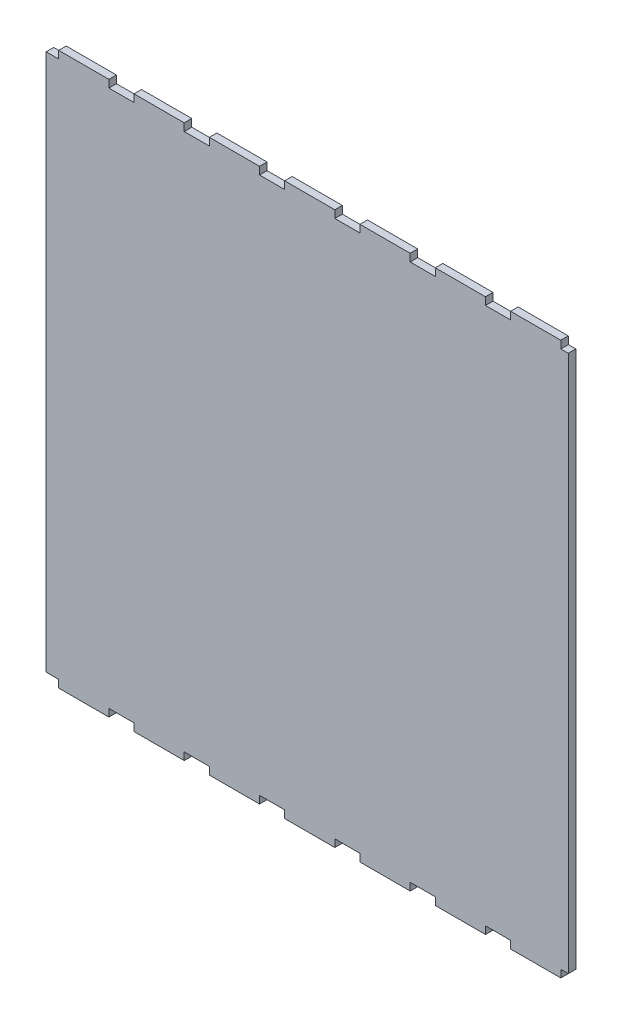
from build123d import *

# Parameters (mm, degrees)
ESQUISSE1_W             = 208
ESQUISSE1_H             = 220
BOSS_EXTRU_1_DEPTH      = 3
ESQUISSE2_W             = 10
ESQUISSE2_H             = 3
ENL_V_MAT_EXTRU_1_DEPTH = 3


with BuildPart() as part:
    # Esquisse1 → Boss.-Extru.1 (new body)
    with BuildSketch(Plane.XY):
        Rectangle(ESQUISSE1_W, ESQUISSE1_H)
    extrude(amount=BOSS_EXTRU_1_DEPTH)

    # Esquisse2 → Enlèv. mat.-Extru.1 (cut)
    with BuildSketch(Plane.XY.offset(3)):
        with Locations((-104, 108.5)):
            Rectangle(ESQUISSE2_W, ESQUISSE2_H)
        with Locations((-74, 108.5)):
            Rectangle(ESQUISSE2_W, ESQUISSE2_H)
        with Locations((-44, 108.5)):
            Rectangle(ESQUISSE2_W, ESQUISSE2_H)
        with Locations((-14, 108.5)):
            Rectangle(ESQUISSE2_W, ESQUISSE2_H)
        with Locations((16, 108.5)):
            Rectangle(ESQUISSE2_W, ESQUISSE2_H)
        with Locations((46, 108.5)):
            Rectangle(ESQUISSE2_W, ESQUISSE2_H)
        with Locations((76, 108.5)):
            Rectangle(ESQUISSE2_W, ESQUISSE2_H)
        with Locations((106, 108.5)):
            Rectangle(ESQUISSE2_W, ESQUISSE2_H)
        with Locations((106, -108.5)):
            Rectangle(ESQUISSE2_W, ESQUISSE2_H)
        with Locations((76, -108.5)):
            Rectangle(ESQUISSE2_W, ESQUISSE2_H)
        with Locations((46, -108.5)):
            Rectangle(ESQUISSE2_W, ESQUISSE2_H)
        with Locations((16, -108.5)):
            Rectangle(ESQUISSE2_W, ESQUISSE2_H)
        with Locations((-14, -108.5)):
            Rectangle(ESQUISSE2_W, ESQUISSE2_H)
        with Locations((-44, -108.5)):
            Rectangle(ESQUISSE2_W, ESQUISSE2_H)
        with Locations((-74, -108.5)):
            Rectangle(ESQUISSE2_W, ESQUISSE2_H)
        with Locations((-104, -108.5)):
            Rectangle(ESQUISSE2_W, ESQUISSE2_H)
    extrude(amount=-ENL_V_MAT_EXTRU_1_DEPTH, mode=Mode.SUBTRACT)


solid = part.part
